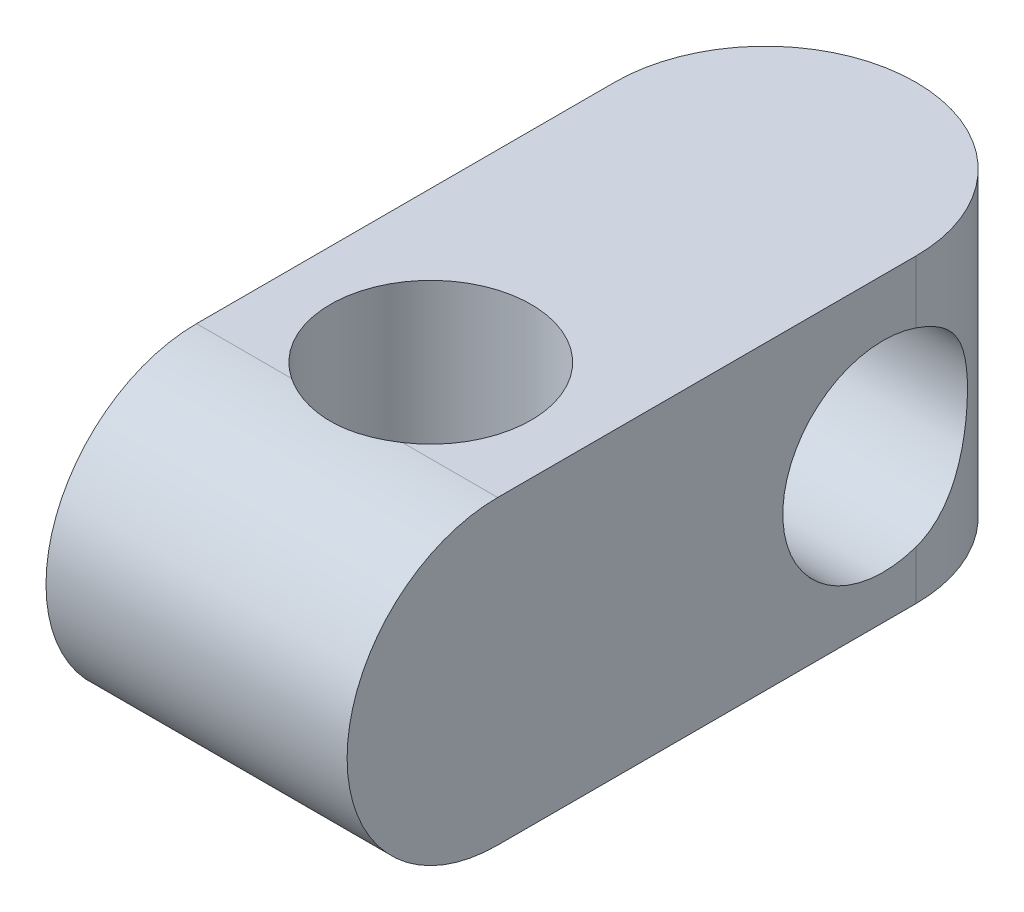
from build123d import *

# Parameters (mm, degrees)
SKETCH1_R           = 6
BOSS_EXTRUDE1_DEPTH = 18
CUT_EXTRUDE3_DEPTH  = 18


with BuildPart() as part:
    # Sketch1 → Boss-Extrude1 (new body)
    with BuildSketch(Plane(origin=(0, 0, 0), x_dir=(1, 0, 0), z_dir=(0, 1, 0))):
        with BuildLine():
            Line((-9, -17), (9, -17))
            Line((9, -17), (9, 17))
            ThreePointArc((9, 17), (0, 26), (-9, 17))
            Line((-9, 17), (-9, -17))
        make_face()
        with Locations(Location((0, -3, 0), (0, 0, 270))):  # turned: the seam where the file's is
            Circle(SKETCH1_R, mode=Mode.SUBTRACT)
    extrude(amount=BOSS_EXTRUDE1_DEPTH)

    # Sketch2 → Cut-Extrude3 (cut)
    with BuildSketch(Plane(origin=(9, 0, 0), x_dir=(0, 0, -1), z_dir=(1, 0, 0))):
        with BuildLine():
            ThreePointArc((-8, 0), (-14.363961031, 2.636038969), (-17, 9))
            Line((-17, 9), (-17, 0))
            Line((-17, 0), (-8, 0))
        make_face()
        with BuildLine():
            ThreePointArc((-17, 9), (-14.363961031, 15.363961031), (-8, 18))
            Line((-8, 18), (-17, 18))
            Line((-17, 18), (-17, 9))
        make_face()
        with BuildLine():
            Line((17, 2.933178288), (17, 14.278790993))
            ThreePointArc((17, 14.278790993), (9.04570522, 8.60598464), (17, 2.933178288))
        make_face()
        with BuildLine():
            ThreePointArc((21.04570522, 8.60598464), (19.930670352, 12.089820982), (17, 14.278790993))
            Line((17, 14.278790993), (17, 2.933178288))
            ThreePointArc((17, 2.933178288), (19.930670352, 5.122148298), (21.04570522, 8.60598464))
        make_face()
    extrude(amount=-CUT_EXTRUDE3_DEPTH, mode=Mode.SUBTRACT)


solid = part.part
